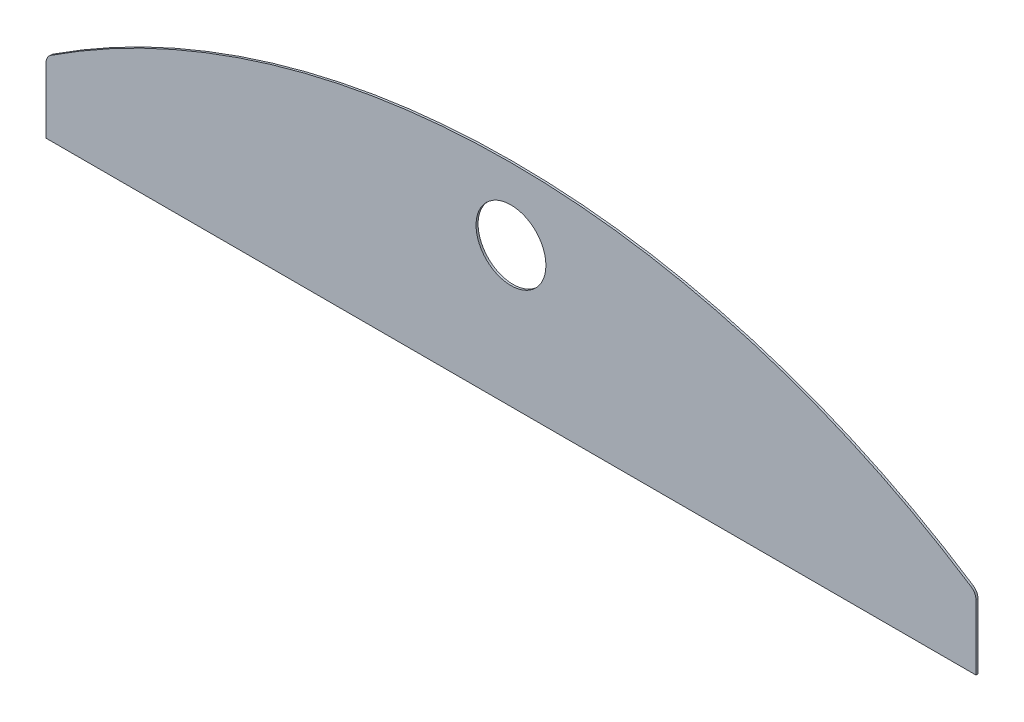
from build123d import *

# Parameters (mm, degrees)
EXTRUDE1_DEPTH     = 1.5
SKETCH2_R          = 25.4
CUT_EXTRUDE1_DEPTH = 2.5


with BuildPart() as part:
    # Sketch1 → Extrude1 (new body)
    with BuildSketch(Plane.XY):
        with BuildLine():
            Line((-338.05, 1029.967766013), (-338.05, 1077.344981378))
            ThreePointArc((-338.05, 1077.344981378), (-337.104806678, 1081.079435118), (-334.496842105, 1083.914581664))
            ThreePointArc((-334.496842105, 1083.914581664), (0, 1183.590029436), (334.496842105, 1083.914581664))
            ThreePointArc((334.496842105, 1083.914581664), (337.104806678, 1081.079435118), (338.05, 1077.344981378))
            Line((338.05, 1077.344981378), (338.05, 1029.967766013))
            Line((338.05, 1029.967766013), (-338.05, 1029.967766013))
        make_face()
    extrude(amount=EXTRUDE1_DEPTH)

    # Sketch2 → Cut-Extrude1 (cut, through all)
    with BuildSketch(Plane.XY.offset(1.5)):
        with Locations((0, 1131.567766013)):
            Circle(SKETCH2_R)
    extrude(amount=-CUT_EXTRUDE1_DEPTH, mode=Mode.SUBTRACT)


solid = part.part
